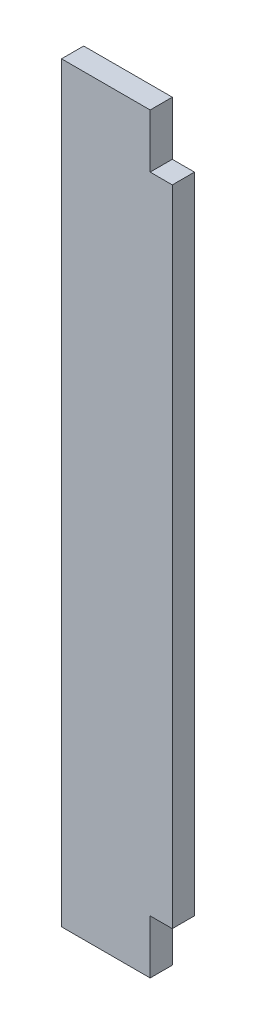
from build123d import *

# Parameters (mm, degrees)
EXTRUDE1_DEPTH = 17.78


with BuildPart() as part:
    # Sketch2 → Extrude1 (new body)
    with BuildSketch(Plane.XY):
        Polygon((11403.541666666, -6411.9125), (11474.661666666, -6411.9125), (11474.661666666, -6368.7325), (11492.441666666, -6368.7325), (11492.441666666, -5851.8425), (11474.661666666, -5851.8425), (11474.661666666, -5808.6625), (11403.541666666, -5808.6625), align=None)
    extrude(amount=-EXTRUDE1_DEPTH)


solid = part.part
